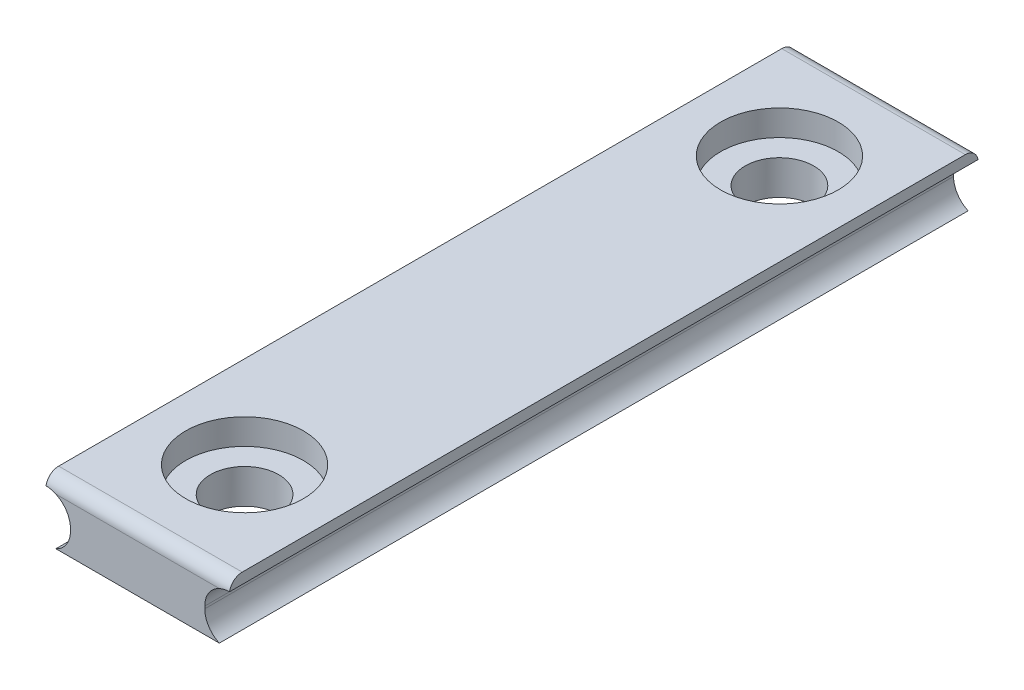
from build123d import *

# Parameters (mm, degrees)
BOSS_EXTRUDE1_DEPTH = 17.5
SKETCH2_R           = 1.6
CUT_EXTRUDE1_DEPTH  = 4.41
SKETCH3_R           = 2.75
CUT_EXTRUDE2_DEPTH  = 1.2
SKETCH4_W           = 8.58
SKETCH4_H           = 35
CUT_EXTRUDE3_DEPTH  = 0.6
FILLET1_R           = 0.6


with BuildPart() as part:
    # Sketch1 → Boss-Extrude1 (new body, symmetric)
    with BuildSketch(Plane.XY):
        with BuildLine():
            Line((-3.14, 0.055), (-3.14, -0.055))
            ThreePointArc((-3.14, -0.055), (-3.476827202, -0.868172798), (-4.29, -1.205))
            Line((-4.29, -1.205), (-4.29, -1.705))
            Line((-4.29, -1.705), (4.29, -1.705))
            Line((4.29, -1.705), (4.29, -1.205))
            ThreePointArc((4.29, -1.205), (3.476827202, -0.868172798), (3.14, -0.055))
            Line((3.14, -0.055), (3.14, 0.055))
            ThreePointArc((3.14, 0.055), (3.476827202, 0.868172798), (4.29, 1.205))
            Line((4.29, 1.205), (4.29, 1.705))
            Line((4.29, 1.705), (-4.29, 1.705))
            Line((-4.29, 1.705), (-4.29, 1.205))
            ThreePointArc((-4.29, 1.205), (-3.476827202, 0.868172798), (-3.14, 0.055))
        make_face()
    extrude(amount=BOSS_EXTRUDE1_DEPTH, both=True)

    # Sketch2 → Cut-Extrude1 (cut, through all)
    with BuildSketch(Plane(origin=(0, 1.705, 0), x_dir=(1, 0, 0), z_dir=(0, 1, 0))):
        with Locations((0, 12.5)):
            Circle(SKETCH2_R)
    cut_extrude1 = extrude(amount=-CUT_EXTRUDE1_DEPTH, mode=Mode.SUBTRACT)

    # Sketch3 → Cut-Extrude2 (cut)
    with BuildSketch(Plane(origin=(0, 1.705, 0), x_dir=(1, 0, 0), z_dir=(0, 1, 0))):
        with Locations((0, 12.5)):
            Circle(SKETCH3_R)
    cut_extrude2 = extrude(amount=-CUT_EXTRUDE2_DEPTH, mode=Mode.SUBTRACT)

    # Mirror1: Cut-Extrude1, Cut-Extrude2 across plane
    add(cut_extrude1.mirror(Plane.XY), mode=Mode.SUBTRACT)
    add(cut_extrude2.mirror(Plane.XY), mode=Mode.SUBTRACT)

    # Sketch4 → Cut-Extrude3 (cut)
    with BuildSketch(Plane.XZ.offset(1.705)):
        Rectangle(SKETCH4_W, SKETCH4_H)
    extrude(amount=-CUT_EXTRUDE3_DEPTH, mode=Mode.SUBTRACT)

    # Fillet1
    fillet1_edges = [part.edges().sort_by_distance(p)[0] for p in [
        (0, 1.705, -17.5),
        (0, 1.705, 17.5),
    ]]
    fillet(fillet1_edges, radius=FILLET1_R)


solid = part.part
